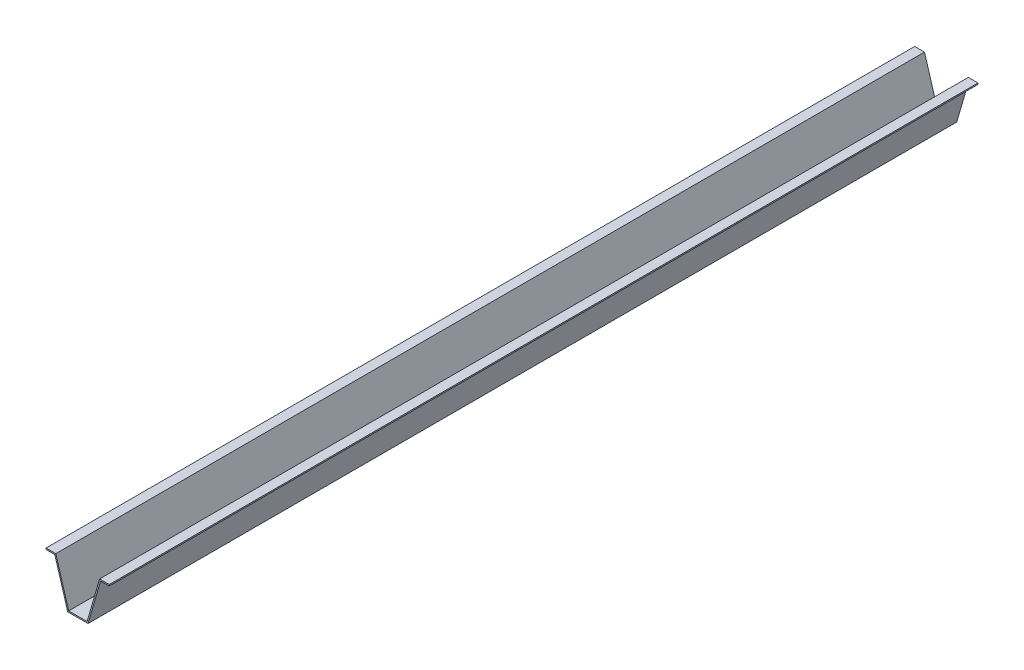
from build123d import *

# Parameters (mm, degrees)
EXTRU_MINCE1_DEPTH = 2000


with BuildPart() as part:
    # Esquisse1 → Extru.-Mince1 (new body)
    with BuildSketch(Plane.XY):
        Polygon((-70.141627462, 26.227685089), (-47.628593052, 26.227685089), (-17.911387629, -73.054796663), (24.413117063, -73.054796663), (53.229801109, 26.227685089), (75.517705176, 26.227685089), (75.517705176, 23.227685089), (55.482865, 23.227685089), (26.666180954, -76.054796663), (-20.144934584, -76.054796663), (-49.862140006, 23.227685089), (-70.141627462, 23.227685089), align=None)
    extrude(amount=EXTRU_MINCE1_DEPTH)


solid = part.part
